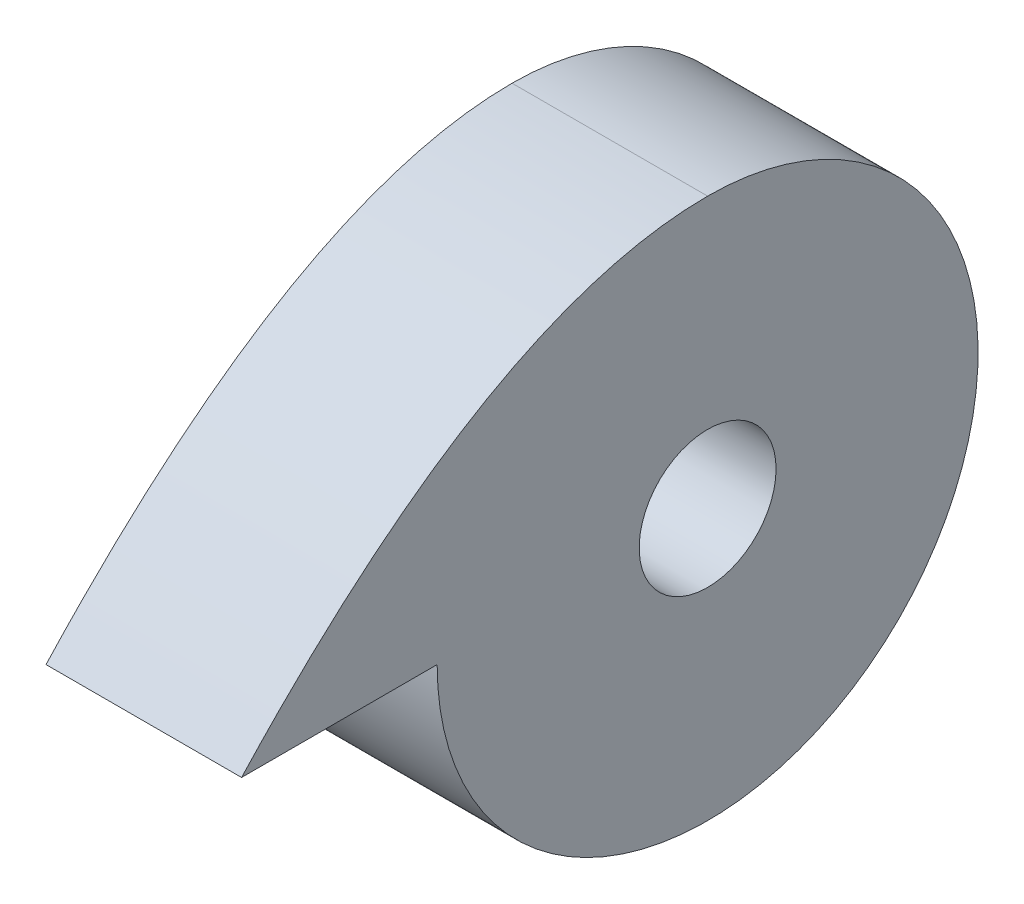
from build123d import *

# Parameters (mm, degrees)
BOSS_EXTRUDE1_DEPTH         = 10
TAP_DRILL_FOR_M8X1_0_TAP1_D = 7


with BuildPart() as part:
    # Sketch1 → Boss-Extrude1 (new body)
    with BuildSketch(Plane(origin=(0, 0, 0), x_dir=(0, 0, -1), z_dir=(1, 0, 0))):
        with BuildLine():
            Line((-47.935100648, 7.446671034), (-57.935100648, 7.446671034))
            add(Edge.make_bspline(
                [(-34.105753338, 21.276018345), (-45.15747621, 21.276018345), (-57.935100648, 7.446671034)],
                knots=[0, 0, 0, 1, 1, 1], degree=2))
            ThreePointArc((-34.105753338, 21.276018345), (-24.326928075, -2.332154228), (-47.935100648, 7.446671034))
        make_face()
    extrude(amount=BOSS_EXTRUDE1_DEPTH)

    # Tap Drill for M8x1.0 Tap1 (through all)
    with Locations(Plane(origin=(10, 0, 0), x_dir=(0, 0, -1), z_dir=(1, 0, 0))):
        with Locations((-34.105753338, 7.446671034)):
            Hole(TAP_DRILL_FOR_M8X1_0_TAP1_D / 2)


solid = part.part
